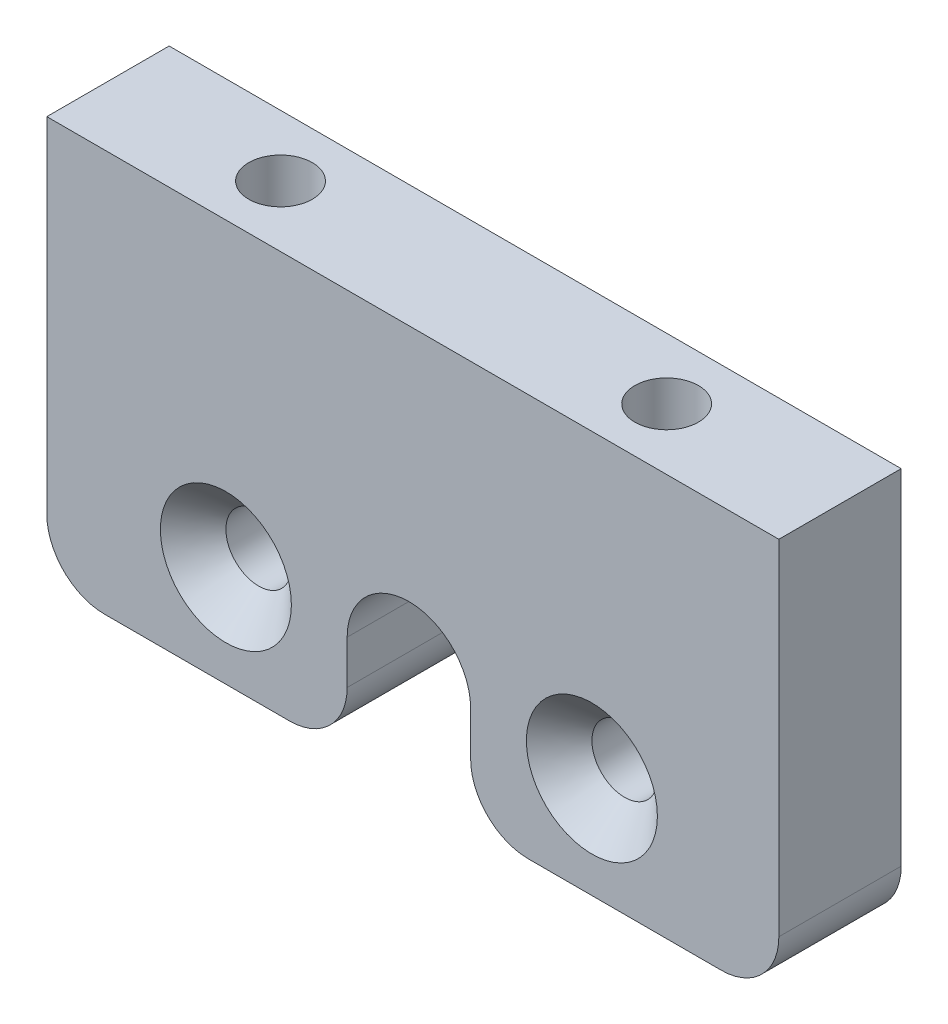
from build123d import *

# Parameters (mm, degrees)
SKETCH1_R           = 1.7
BOSS_EXTRUDE1_DEPTH = 6.35
CHAMFER1_SIZE       = 1.7
SKETCH2_R           = 1.65
CUT_EXTRUDE1_DEPTH  = 10
FILLET1_R           = 3


with BuildPart() as part:
    # Sketch1 → Boss-Extrude1 (new body)
    with BuildSketch(Plane(origin=(7.6e-08, 0, -21.644897171), x_dir=(1, 0, 4e-09), z_dir=(-4e-09, 0, 1))):
        with BuildLine():
            Line((3.000021754, 7.262533291), (3.000021754, 1.9987))
            Line((3.000021754, 1.9987), (19.00000025, 1.9987))
            Line((19.00000025, 1.9987), (19.00000025, 22.8687))
            Line((19.00000025, 22.8687), (-19.00000025, 22.8687))
            Line((-19.00000025, 22.8687), (-19.00000025, 1.9987))
            Line((-19.00000025, 1.9987), (-3.409734271, 1.9987))
            Line((-3.409734271, 1.9987), (-3.409734271, 7.262533291))
            ThreePointArc((-3.409734271, 7.262533291), (-0.204856259, 10.467411304), (3.000021754, 7.262533291))
        make_face()
        with Locations((9.295143741, 7.262533291)):
            Circle(SKETCH1_R, mode=Mode.SUBTRACT)
        with Locations((-9.704856259, 7.262533291)):
            Circle(SKETCH1_R, mode=Mode.SUBTRACT)
    extrude(amount=BOSS_EXTRUDE1_DEPTH)

    # Chamfer1
    chamfer1_edges = [part.edges().sort_by_distance(p)[0] for p in [
        (7.595143795, 7.262533291, -15.294897144),
        (-11.404856205, 7.262533291, -15.294897211),
    ]]
    chamfer(chamfer1_edges, length=CHAMFER1_SIZE)

    # Sketch2 → Cut-Extrude1 (cut)
    with BuildSketch(Plane(origin=(0, 22.8687, 0), x_dir=(1, 0, 0), z_dir=(0, 1, 0))):
        with Locations((10, 18.469897104)):
            Circle(SKETCH2_R)
        with Locations((-10.042850258, 18.469897104)):
            Circle(SKETCH2_R)
    extrude(amount=-CUT_EXTRUDE1_DEPTH, mode=Mode.SUBTRACT)

    # Fillet1
    fillet1_edges = [part.edges().sort_by_distance(p)[0] for p in [
        (-3.409734206, 1.9987, -18.469897183),
        (-19.000000186, 1.9987, -18.469897237),
        (19.000000315, 1.9987, -18.469897104),
        (3.000021818, 1.9987, -18.46989716),
    ]]
    fillet(fillet1_edges, radius=FILLET1_R)


solid = part.part
